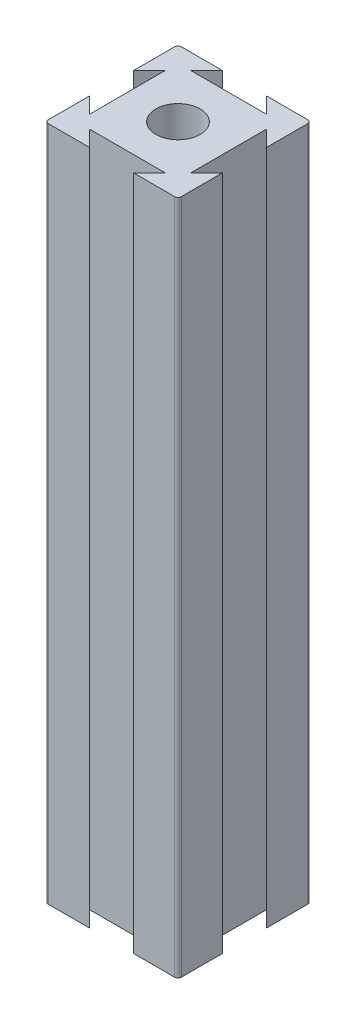
from build123d import *

# Parameters (mm, degrees)
SKETCH1_R           = 3.333333333
BOSS_EXTRUDE1_DEPTH = 101.6
FILLET4_R           = 0.508


with BuildPart() as part:
    # Sketch1 → Boss-Extrude1 (new body)
    with BuildSketch(Plane(origin=(0, 0, 0), x_dir=(1, 0, 0), z_dir=(0, 1, 0))):
        Polygon((4.285, 17.618333333), (6.666666667, 20), (0, 20), (0, 13.333333333), (2.381666667, 15.715), (2.381666667, 4.285), (0, 6.666666667), (0, 0), (6.666666667, 0), (4.285, 2.381666667), (15.715, 2.381666667), (13.333333333, 0), (20, 0), (20, 6.666666667), (17.618333333, 4.285), (17.618333333, 15.715), (20, 13.333333333), (20, 20), (13.333333333, 20), (15.715, 17.618333333), align=None)
        with Locations((10, 10)):
            Circle(SKETCH1_R, mode=Mode.SUBTRACT)
    extrude(amount=BOSS_EXTRUDE1_DEPTH)

    # Fillet4
    fillet4_edges = [part.edges().sort_by_distance(p)[0] for p in [
        (20, 50.8, 0),
        (0, 50.8, 0),
        (0, 50.8, -20),
        (20, 50.8, -20),
    ]]
    fillet(fillet4_edges, radius=FILLET4_R)


solid = part.part
